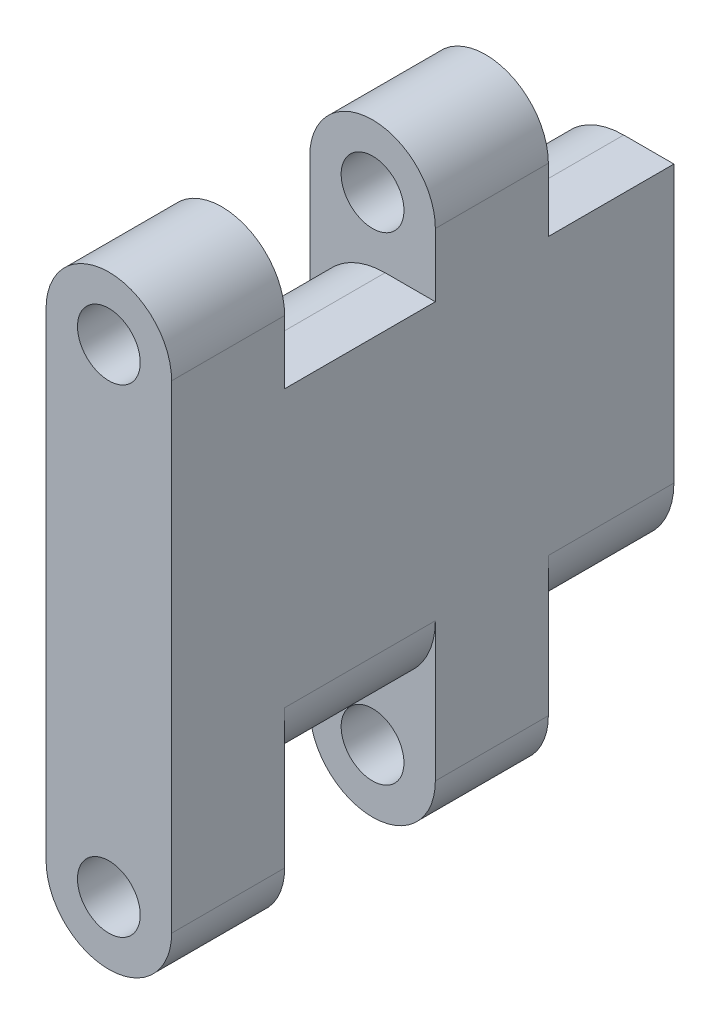
from build123d import *

# Parameters (mm, degrees)
SKETCH1_W           = 40
SKETCH1_H           = 28
BOSS_EXTRUDE1_DEPTH = 10
SKETCH2_R           = 2.5
BOSS_EXTRUDE2_DEPTH = 9
LPATTERN1_COUNT     = 2
LPATTERN1_PITCH     = 21
FILLET1_R           = 6


with BuildPart() as part:
    # Sketch1 → Boss-Extrude1 (new body)
    with BuildSketch(Plane(origin=(0, 0, 0), x_dir=(0, 0, -1), z_dir=(1, 0, 0))):
        Rectangle(SKETCH1_W, SKETCH1_H)
    extrude(amount=BOSS_EXTRUDE1_DEPTH)

    # Sketch2 → Boss-Extrude2 (add)
    with BuildSketch(Plane.XY.offset(20)):
        with BuildLine():
            Line((10, 19.05), (10, -19.05))
            ThreePointArc((10, -19.05), (5, -24.05), (0, -19.05))
            Line((0, -19.05), (0, 19.05))
            ThreePointArc((0, 19.05), (5, 24.05), (10, 19.05))
        make_face()
        with Locations((5, 19.05)):
            Circle(SKETCH2_R, mode=Mode.SUBTRACT)
        with Locations((5, -19.05)):
            Circle(SKETCH2_R, mode=Mode.SUBTRACT)
    boss_extrude2 = extrude(amount=-BOSS_EXTRUDE2_DEPTH)

    # LPattern1: Boss-Extrude2 ×2
    with Locations(*[(0, 0, -i * LPATTERN1_PITCH) for i in range(1, LPATTERN1_COUNT)]):
        add(boss_extrude2)

    # Fillet1
    fillet1_edges = [part.edges().sort_by_distance(p)[0] for p in [
        (10, -14, 5),
        (0, 14, 5),
        (10, -14, -15),
        (0, 14, -15),
    ]]
    fillet(fillet1_edges, radius=FILLET1_R)


solid = part.part
